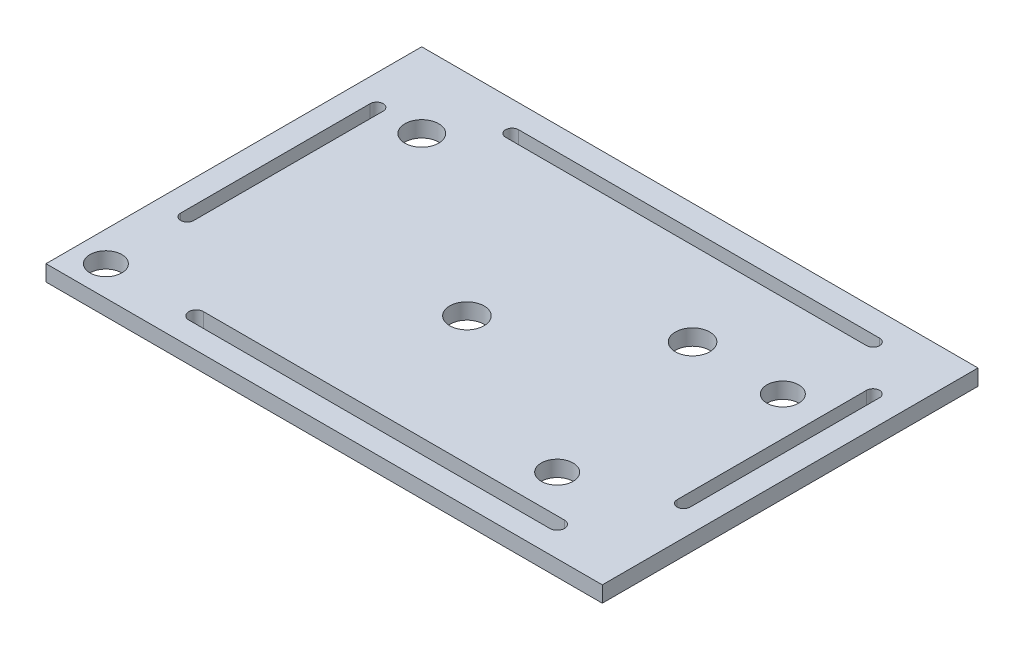
from build123d import *

# Parameters (mm, degrees)
SKETCH1_W           = 110.936328641
SKETCH1_H           = 74.919128642
BOSS_EXTRUDE1_DEPTH = 3.175
SKETCH2_R           = 3.175
CUT_EXTRUDE1_DEPTH  = 4.175
SKETCH10_R          = 3.175
CUT_EXTRUDE5_DEPTH  = 4.175
CUT_EXTRUDE6_DEPTH  = 4.175
SKETCH12_R          = 3.370079304
SKETCH12_R_2        = 3.429
CUT_EXTRUDE7_DEPTH  = 4.175


with BuildPart() as part:
    # Sketch1 → Boss-Extrude1 (new body)
    with BuildSketch(Plane(origin=(0, 0, 0), x_dir=(1, 0, 0), z_dir=(0, 1, 0))):
        with Locations((-27.986559238, -0.898578046)):
            Rectangle(SKETCH1_W, SKETCH1_H)
    extrude(amount=BOSS_EXTRUDE1_DEPTH)

    # Sketch2 → Cut-Extrude1 (cut, through all)
    with BuildSketch(Plane.XZ):
        with Locations((-77.473379238, 32.394578046)):
            Circle(SKETCH2_R)
    extrude(amount=-CUT_EXTRUDE1_DEPTH, mode=Mode.SUBTRACT)

    # Sketch10 → Cut-Extrude5 (cut, through all)
    with BuildSketch(Plane(origin=(0, 3.175, 0), x_dir=(1, 0, 0), z_dir=(0, 1, 0))):
        with Locations((3.519600762, -23.395358046)):
            Circle(SKETCH10_R)
        with Locations((12.518820762, 12.601521954)):
            Circle(SKETCH10_R)
    extrude(amount=-CUT_EXTRUDE5_DEPTH, mode=Mode.SUBTRACT)

    # Sketch11 → Cut-Extrude6 (cut, through all)
    with BuildSketch(Plane(origin=(0, 3.175, 0), x_dir=(1, 0, 0), z_dir=(0, 1, 0))):
        with BuildLine():
            Line((-78.770441311, -16.175423663), (-78.770441311, 21.600741954))
            ThreePointArc((-78.770441311, 21.600741954), (-77.473379238, 22.897804027), (-76.176317164, 21.600741954))
            Line((-76.176317164, 21.600741954), (-76.176317164, -16.175423663))
            ThreePointArc((-76.176317164, -16.175423663), (-77.473379238, -17.472485737), (-78.770441311, -16.175423663))
        make_face()
        with BuildLine():
            Line((-59.474939238, 31.899342378), (12.518820762, 31.899342378))
            ThreePointArc((12.518820762, 31.899342378), (13.818201186, 30.599961954), (12.518820762, 29.30058153))
            Line((12.518820762, 29.30058153), (-59.474939238, 29.30058153))
            ThreePointArc((-59.474939238, 29.30058153), (-60.774319661, 30.599961954), (-59.474939238, 31.899342378))
        make_face()
        with BuildLine():
            Line((12.518820762, -33.852545554), (-59.474939238, -33.852545554))
            ThreePointArc((-59.474939238, -33.852545554), (-60.932906745, -32.394578046), (-59.474939238, -30.936610538))
            Line((-59.474939238, -30.936610538), (12.518820762, -30.936610538))
            ThreePointArc((12.518820762, -30.936610538), (13.97678827, -32.394578046), (12.518820762, -33.852545554))
        make_face()
        with BuildLine():
            Line((20.226413943, -16.175423663), (20.226413943, 21.600741954))
            ThreePointArc((20.226413943, 21.600741954), (21.518040762, 22.892368774), (22.809667582, 21.600741954))
            Line((22.809667582, 21.600741954), (22.809667582, -16.175423663))
            ThreePointArc((22.809667582, -16.175423663), (21.518040762, -17.467050483), (20.226413943, -16.175423663))
        make_face()
    extrude(amount=-CUT_EXTRUDE6_DEPTH, mode=Mode.SUBTRACT)

    # Sketch12 → Cut-Extrude7 (cut, through all)
    with BuildSketch(Plane(origin=(0, 3.175, 0), x_dir=(1, 0, 0), z_dir=(0, 1, 0))):
        with Locations((-68.474159238, 21.600741954)):
            Circle(SKETCH12_R)
        with Locations((-32.477279238, -5.396918046)):
            Circle(SKETCH12_R_2)
        with Locations((-5.479619238, 12.601521954)):
            Circle(SKETCH12_R_2)
    extrude(amount=-CUT_EXTRUDE7_DEPTH, mode=Mode.SUBTRACT)


solid = part.part
